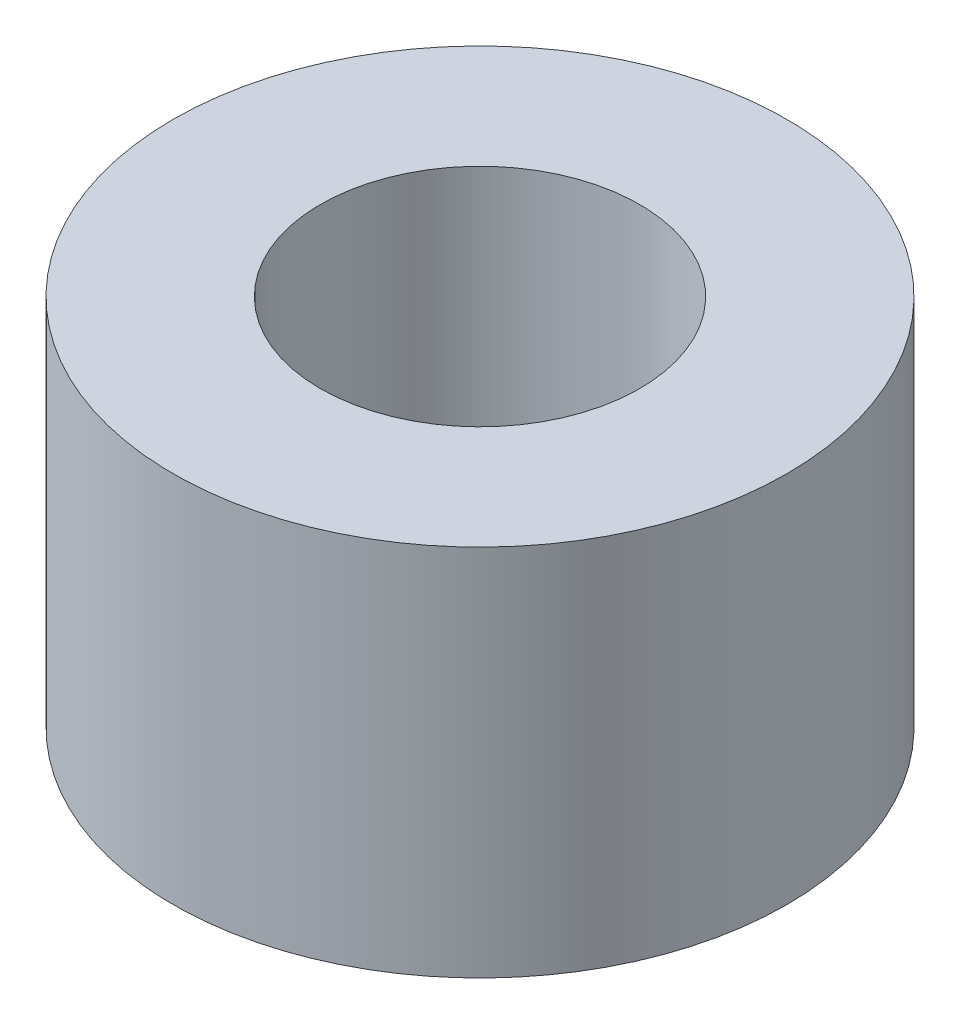
from build123d import *

# Parameters (mm, degrees)
SKETCH1_R           = 6.25
SKETCH1_R_2         = 3.25
EXTRUDE_THIN1_DEPTH = 7.6


with BuildPart() as part:
    # Sketch1 → Extrude-Thin1 (new body)
    with BuildSketch(Plane(origin=(0, 0, 0), x_dir=(1, 0, 0), z_dir=(0, 1, 0))):
        Circle(SKETCH1_R)
        Circle(SKETCH1_R_2, mode=Mode.SUBTRACT)
    extrude(amount=EXTRUDE_THIN1_DEPTH)


solid = part.part
